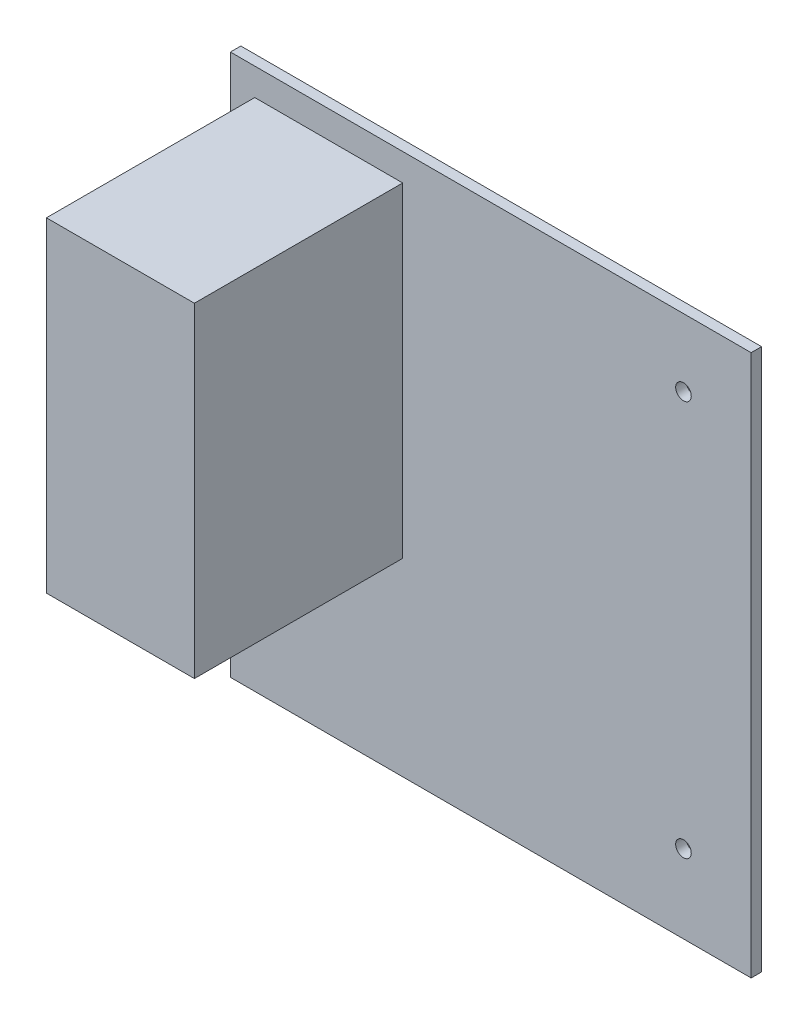
from build123d import *

# Parameters (mm, degrees)
SKETCH1_W           = 100
SKETCH1_H           = 104
BOSS_EXTRUDE1_DEPTH = 2
SKETCH2_R           = 1.5
CUT_EXTRUDE1_DEPTH  = 2
SKETCH3_W           = 28.414936843
SKETCH3_H           = 62.425741265
BOSS_EXTRUDE2_DEPTH = 40


with BuildPart() as part:
    # Sketch1 → Boss-Extrude1 (new body)
    with BuildSketch(Plane.XY):
        Rectangle(SKETCH1_W, SKETCH1_H)
    extrude(amount=BOSS_EXTRUDE1_DEPTH)

    # Sketch2 → Cut-Extrude1 (cut)
    with BuildSketch(Plane.XY.offset(2)):
        with Locations((-44, -37)):
            Circle(SKETCH2_R)
        with Locations((37, -37)):
            Circle(SKETCH2_R)
        with Locations((37, 39)):
            Circle(SKETCH2_R)
    extrude(amount=-CUT_EXTRUDE1_DEPTH, mode=Mode.SUBTRACT)

    # Sketch3 → Boss-Extrude2 (add)
    with BuildSketch(Plane.XY.offset(2)):
        with Locations((-31.124449574, 15.550972076)):
            Rectangle(SKETCH3_W, SKETCH3_H)
    extrude(amount=BOSS_EXTRUDE2_DEPTH)


solid = part.part
